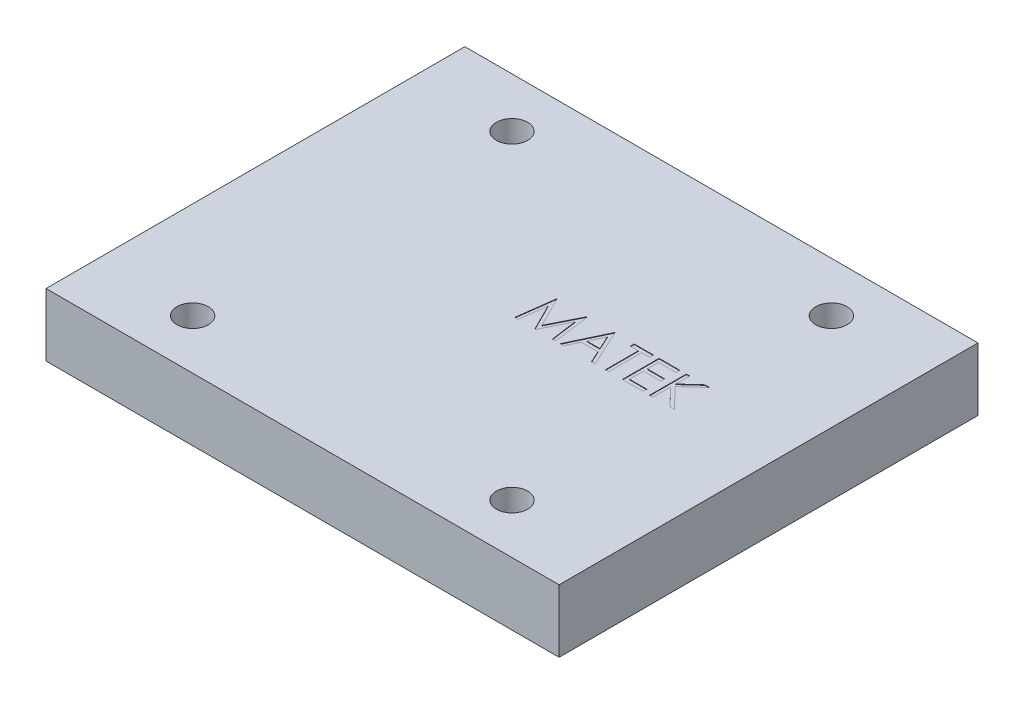
from build123d import *

# Parameters (mm, degrees)
SKETCH1_W           = 49
SKETCH1_H           = 40
SKETCH1_R           = 1.5
BOSS_EXTRUDE1_DEPTH = 6
CUT_EXTRUDE1_DEPTH  = 0.05


with BuildPart() as part:
    # Sketch1 → Boss-Extrude1 (new body)
    with BuildSketch(Plane(origin=(0, 0, 0), x_dir=(1, 0, 0), z_dir=(0, 1, 0))):
        Rectangle(SKETCH1_W, SKETCH1_H)
        with Locations((-15.25, 15.25)):
            Circle(SKETCH1_R, mode=Mode.SUBTRACT)
        with Locations((15.25, 15.25)):
            Circle(SKETCH1_R, mode=Mode.SUBTRACT)
        with Locations((15.25, -15.25)):
            Circle(SKETCH1_R, mode=Mode.SUBTRACT)
        with Locations((-15.25, -15.25)):
            Circle(SKETCH1_R, mode=Mode.SUBTRACT)
    extrude(amount=BOSS_EXTRUDE1_DEPTH)

    # Sketch2 → Cut-Extrude1 (cut)
    with BuildSketch(Plane(origin=(0, 6, 0), x_dir=(1, 0, 0), z_dir=(0, 1, 0))):
        Polygon((0.269230769, 0), (0.731270032, 3.5), (0.776141827, 3.5), (2.221153846, 0.628205128), (3.661959135, 3.5), (3.706830929, 3.5), (4.173076923, 0), (3.858974359, 0), (3.522435897, 2.516326122), (2.259715545, 0), (2.188201122, 0), (0.919871795, 2.524038462), (0.585436699, 0), align=None)
        Polygon((6.326923077, 3.5), (7.942307692, 0), (7.600861378, 0), (7.083433494, 1.121794872), (5.496794872, 1.121794872), (4.965344551, 0), (4.621794872, 0), (6.282051282, 3.5), align=None)
        Polygon((6.300981571, 2.817107372), (5.66786859, 1.480769231), (6.91796875, 1.480769231), align=None, mode=Mode.SUBTRACT)
        Polygon((8.166666667, 3.141025641), (8.166666667, 3.5), (10.006410256, 3.5), (10.006410256, 3.141025641), (9.243589744, 3.141025641), (9.243589744, 0), (8.929487179, 0), (8.929487179, 3.141025641), align=None)
        Polygon((10.544871795, 3.5), (12.519230769, 3.5), (12.519230769, 3.141025641), (10.858974359, 3.141025641), (10.858974359, 2.064102564), (12.519230769, 2.064102564), (12.519230769, 1.705128205), (10.858974359, 1.705128205), (10.858974359, 0.358974359), (12.519230769, 0.358974359), (12.519230769, 0), (10.544871795, 0), align=None)
        Polygon((13.147435897, 3.5), (13.461538462, 3.5), (13.461538462, 2.167167468), (14.920572917, 3.5), (15.368589744, 3.5), (13.648737981, 1.929487179), (15.503205128, 0), (15.083934295, 0), (13.461538462, 1.689002404), (13.461538462, 0), (13.147435897, 0), align=None)
    extrude(amount=-CUT_EXTRUDE1_DEPTH, mode=Mode.SUBTRACT)


solid = part.part
